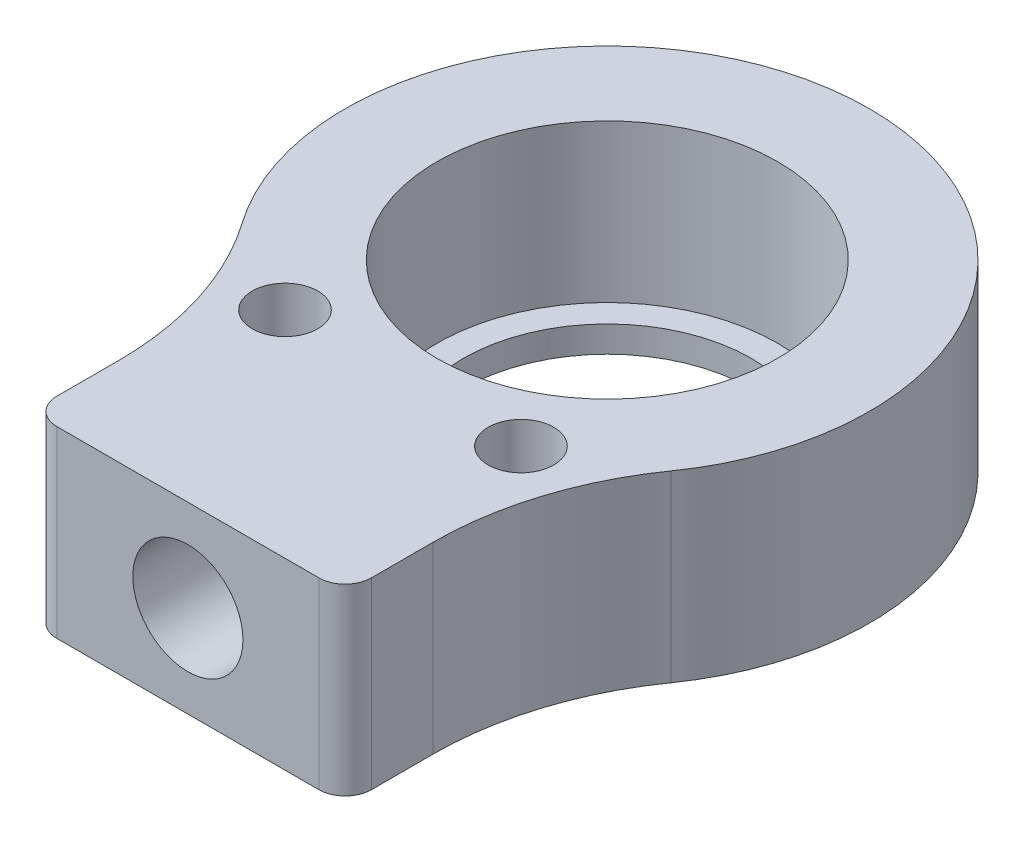
from build123d import *

# Parameters (mm, degrees)
ESQUISSE1_R             = 10
ESQUISSE1_R_2           = 5.5
BOSS_EXTRU_1_DEPTH      = 7
ESQUISSE2_R             = 6.5
ENL_V_MAT_EXTRU_1_DEPTH = 6
ESQUISSE7_W             = 12
ESQUISSE7_H             = 8
BOSS_EXTRU_2_DEPTH      = 7
CONG_1_R                = 12
TROU_TARAUD_M31_D       = 2.5
TROU_TARAUD_M51_D       = 4.2
TROU_TARAUD_M51_DEPTH   = 16
TROU_TARAUD_M51_TIP     = 1.2618073
CONG_2_R                = 1


with BuildPart() as part:
    # Esquisse1 → Boss.-Extru.1 (new body)
    with BuildSketch(Plane(origin=(0, 0, 0), x_dir=(1, 0, 0), z_dir=(0, 1, 0))):
        with Locations(Location((0, 0, 0), (0, 0, 270))):  # turned: the seam where the file's is
            Circle(ESQUISSE1_R)
        with Locations(Location((0, 0, 0), (0, 0, 270))):  # turned: the seam where the file's is
            Circle(ESQUISSE1_R_2, mode=Mode.SUBTRACT)
    extrude(amount=BOSS_EXTRU_1_DEPTH)

    # Esquisse2 → Enlèv. mat.-Extru.1 (cut)
    with BuildSketch(Plane(origin=(0, 7, 0), x_dir=(1, 0, 0), z_dir=(0, 1, 0))):
        with Locations(Location((0, 0, 0), (0, 0, 270))):  # turned: the seam where the file's is
            Circle(ESQUISSE2_R)
    extrude(amount=-ENL_V_MAT_EXTRU_1_DEPTH, mode=Mode.SUBTRACT)

    # Esquisse7 → Boss.-Extru.2 (add)
    with BuildSketch(Plane(origin=(0, 0, 0), x_dir=(1, 0, 0), z_dir=(0, 1, 0))):
        with Locations((0, -12)):
            Rectangle(ESQUISSE7_W, ESQUISSE7_H)
    extrude(amount=BOSS_EXTRU_2_DEPTH)

    # Congé1
    cong_1_edges = [part.edges().sort_by_distance(p)[0] for p in [
        (-6, 3.5, 8),
        (6, 3.5, 8),
    ]]
    fillet(cong_1_edges, radius=CONG_1_R)

    # Trou taraudé M31 (through all)
    with Locations(Plane(origin=(0, 7, 0), x_dir=(1, 0, 0), z_dir=(0, 1, 0))):
        with Locations((4.5, -7.794228634), (-4.5, -7.794228634)):
            Hole(TROU_TARAUD_M31_D / 2)

    # Trou taraudé M51
    with Locations(Plane.XY.offset(16)):
        with Locations((0, 3.5)):
            Hole(TROU_TARAUD_M51_D / 2, depth=TROU_TARAUD_M51_DEPTH)
            with Locations((0, 0, -(TROU_TARAUD_M51_DEPTH + TROU_TARAUD_M51_TIP / 2))):  # 118° drill point
                Cone(0, TROU_TARAUD_M51_D / 2, TROU_TARAUD_M51_TIP, mode=Mode.SUBTRACT)

    # Congé2
    cong_2_edges = [part.edges().sort_by_distance(p)[0] for p in [
        (-6, 3.5, 16),
        (6, 3.5, 16),
    ]]
    fillet(cong_2_edges, radius=CONG_2_R)


solid = part.part
